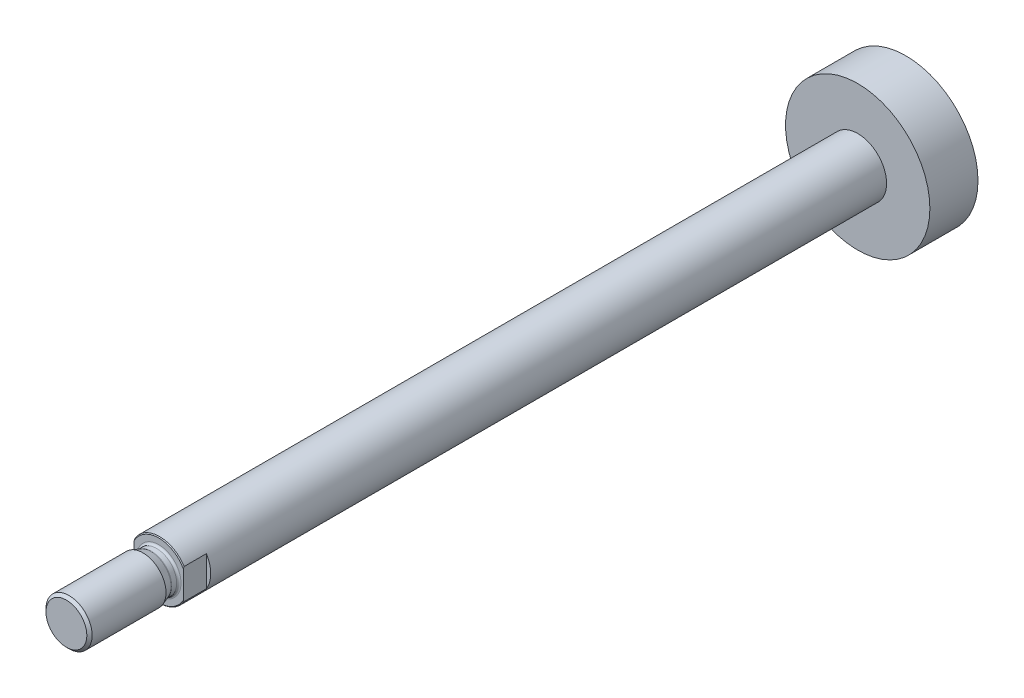
from build123d import *

# Parameters (mm, degrees)
CUT_EXTRUDE1_DEPTH      = 17
CUT_EXTRUDE1_DEPTH_BACK = 17


with BuildPart() as part:
    # Sketch1 → Revolve1 (revolve)
    with BuildSketch(Plane(origin=(0, 0, 0), x_dir=(0, 0, -1), z_dir=(1, 0, 0))):
        Polygon((-35.8, 0), (-35.8, 9.717157288), (-35.517157288, 10), (206.333333333, 10), (206.333333333, 25), (223, 25), (223, 0), align=None)
    revolve(axis=Axis((0, 0, -223), (0, 0, 1)))

    # Sketch2 → Cut-Extrude1 (cut, two sides: drawn at the far end of the back side and taken through both)
    with BuildSketch(Plane(origin=(0, 0, 0), x_dir=(1, 0, 0), z_dir=(0, 1, 0)).offset(-CUT_EXTRUDE1_DEPTH_BACK)):
        Polygon((-17, -61.8), (17, -61.8), (17, -27.8), (8.5, -27.8), (8.5, -43.8), (-8.5, -43.8), (-8.5, -27.8), (-17, -27.8), align=None)
    extrude(amount=CUT_EXTRUDE1_DEPTH + CUT_EXTRUDE1_DEPTH_BACK, mode=Mode.SUBTRACT)

    # Sketch3 → Revolve2 (revolve)
    with BuildSketch(Plane(origin=(0, 0, 0), x_dir=(0, 0, -1), z_dir=(1, 0, 0))):
        with BuildLine():
            Line((-67.8, 0), (-67.8, 7.08))
            Line((-67.8, 7.08), (-66.88, 8))
            Line((-66.88, 8), (-41.28485129, 8))
            Line((-41.28485129, 8), (-38.524269872, 6.995230534))
            ThreePointArc((-38.524269872, 6.995230534), (-38.397990898, 6.961394185), (-38.267754764, 6.95))
            Line((-38.267754764, 6.95), (-36.55, 6.95))
            ThreePointArc((-36.55, 6.95), (-36.019669914, 7.169669914), (-35.8, 7.7))
            Line((-35.8, 7.7), (-35.05, 7.7))
            Line((-35.05, 7.7), (-35.05, 0))
            Line((-35.05, 0), (-67.8, 0))
        make_face()
    revolve(axis=Axis((0, 0, 35.05), (0, 0, 1)))


solid = part.part
